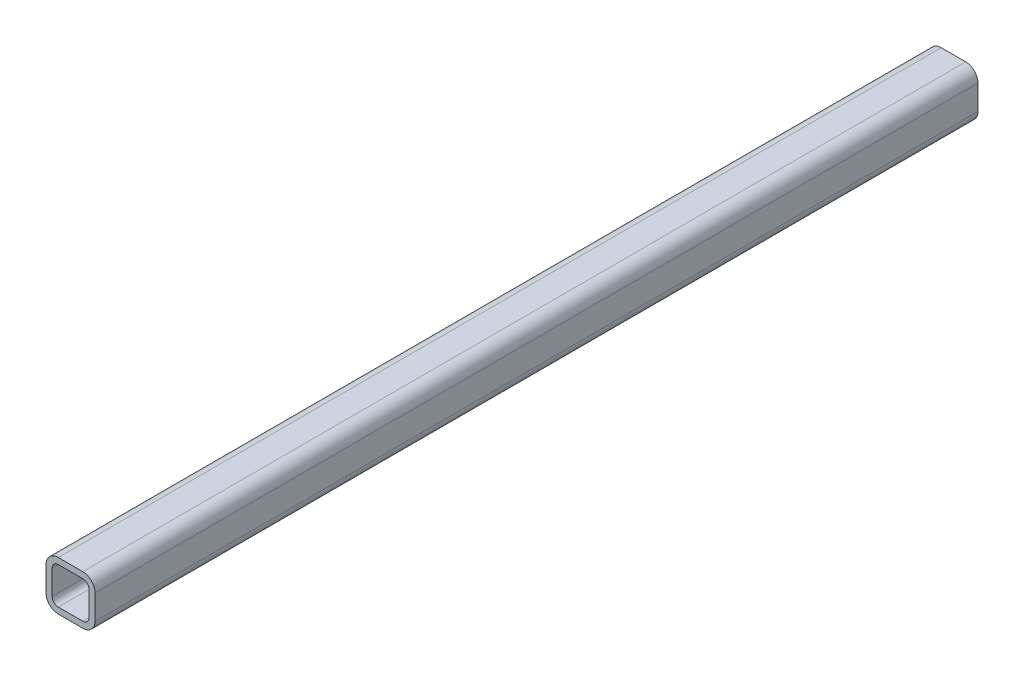
from build123d import *

# Parameters (mm, degrees)
BOSS_EXTRUDE1_DEPTH = 457.2


with BuildPart() as part:
    # Sketch1 → Boss-Extrude1 (new body, symmetric)
    with BuildSketch(Plane.XY):
        with BuildLine():
            Line((12.7, 0), (38.1, 0))
            ThreePointArc((38.1, 0), (47.080256121, 3.719743879), (50.8, 12.7))
            Line((50.8, 12.7), (50.8, 38.1))
            ThreePointArc((50.8, 38.1), (47.080256121, 47.080256121), (38.1, 50.8))
            Line((38.1, 50.8), (12.7, 50.8))
            ThreePointArc((12.7, 50.8), (3.719743879, 47.080256121), (0, 38.1))
            Line((0, 38.1), (0, 12.7))
            ThreePointArc((0, 12.7), (3.719743879, 3.719743879), (12.7, 0))
        make_face()
        with BuildLine():
            Line((12.7, 6.35), (38.1, 6.35))
            ThreePointArc((38.1, 6.35), (42.590128061, 8.209871939), (44.45, 12.7))
            Line((44.45, 12.7), (44.45, 38.1))
            ThreePointArc((44.45, 38.1), (42.590128061, 42.590128061), (38.1, 44.45))
            Line((38.1, 44.45), (12.7, 44.45))
            ThreePointArc((12.7, 44.45), (8.209871939, 42.590128061), (6.35, 38.1))
            Line((6.35, 38.1), (6.35, 12.7))
            ThreePointArc((6.35, 12.7), (8.209871939, 8.209871939), (12.7, 6.35))
        make_face(mode=Mode.SUBTRACT)
    extrude(amount=BOSS_EXTRUDE1_DEPTH, both=True)


solid = part.part
